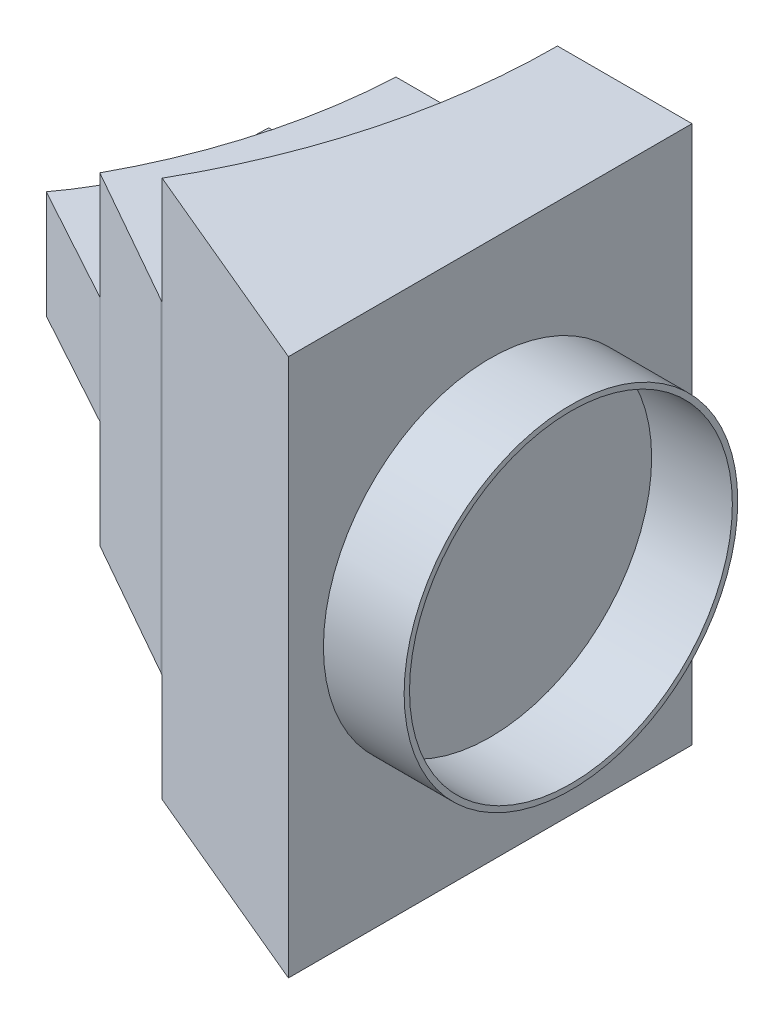
from build123d import *

# Parameters (mm, degrees)
BOSS_EXTRUDE1_DEPTH = 60
BOSS_EXTRUDE2_DEPTH = 10
BOSS_EXTRUDE3_DEPTH = 50
SKETCH6_R           = 31
SKETCH6_R_2         = 30
BOSS_EXTRUDE4_DEPTH = 15


with BuildPart() as part:
    # Sketch3 → Boss-Extrude1 (new body)
    with BuildSketch(Plane(origin=(0, 0, 0), x_dir=(1, 0, 0), z_dir=(0, 1, 0))):
        with BuildLine():
            Line((87.760961666, -47.937601186), (113.87798128, -62.699081006))
            Line((113.87798128, -62.699081006), (114.406801927, -63.002726521))
            ThreePointArc((114.406801927, -63.002726521), (125.941479433, -35.014908861), (129.874921777, -5))
            Line((129.874921777, -5), (99.874921777, -5))
            ThreePointArc((99.874921777, -5), (98.598858001, -16.681282954), (95.96133419, -28.132229568))
            ThreePointArc((95.96133419, -28.132229568), (92.393363857, -38.255278265), (87.760961666, -47.937601186))
        make_face()
    extrude(amount=BOSS_EXTRUDE1_DEPTH)

    # Sketch4 → Boss-Extrude2 (add, symmetric)
    with BuildSketch(Plane(origin=(0, 30, 0), x_dir=(1, 0, 0), z_dir=(0, 1, 0))):
        with BuildLine():
            Line((87.760961666, -47.937601186), (65.820721249, -35.95320089))
            ThreePointArc((65.820721249, -35.95320089), (73.538888161, -21.324139043), (76.203852603, -5))
            Line((76.203852603, -5), (99.874921777, -5))
            ThreePointArc((99.874921777, -5), (96.243002799, -27.152981645), (87.760961666, -47.937601186))
        make_face()
    extrude(amount=BOSS_EXTRUDE2_DEPTH, both=True)

    # Sketch5 → Boss-Extrude3 (add, symmetric)
    with BuildSketch(Plane(origin=(0, 30, 0), x_dir=(1, 0, 0), z_dir=(0, 1, 0))):
        with BuildLine():
            Line((129.874921777, -5), (154.874921777, -5))
            Line((154.874921777, -5), (154.874921777, -63.002726521))
            Line((154.874921777, -63.002726521), (154.874921777, -80))
            Line((154.874921777, -80), (114.406801927, -63.002726521))
            ThreePointArc((114.406801927, -63.002726521), (125.941479433, -35.014908861), (129.874921777, -5))
        make_face()
    extrude(amount=BOSS_EXTRUDE3_DEPTH, both=True)

    # Sketch6 → Boss-Extrude4 (add)
    with BuildSketch(Plane(origin=(154.874921777, 0, 0), x_dir=(0, 0, -1), z_dir=(1, 0, 0))):
        with Locations((-42.5, 30)):
            Circle(SKETCH6_R)
        with Locations((-42.5, 30)):
            Circle(SKETCH6_R_2, mode=Mode.SUBTRACT)
    extrude(amount=BOSS_EXTRUDE4_DEPTH)


solid = part.part
